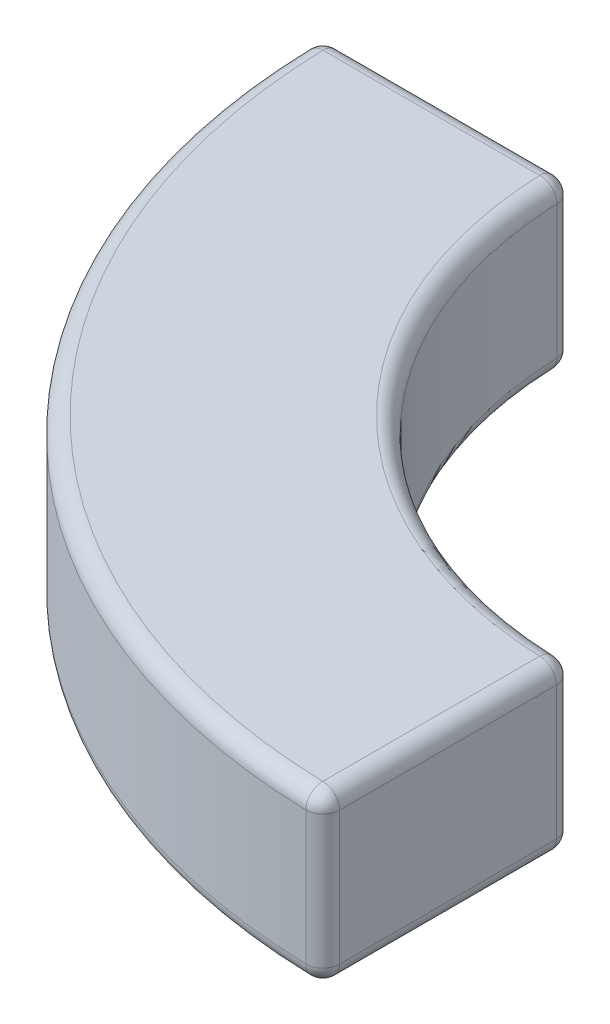
from build123d import *

# Parameters (mm, degrees)
BOSS_EXTRUDE1_DEPTH = 5
FILLET1_R           = 0.5


with BuildPart() as part:
    # Sketch1 → Boss-Extrude1 (new body)
    with BuildSketch(Plane(origin=(0, 0, 0), x_dir=(1, 0, 0), z_dir=(0, 1, 0))):
        with BuildLine():
            Line((-12.5, 0), (-20, 0))
            ThreePointArc((-20, 0), (-14.142135624, -14.142135624), (0, -20))
            Line((0, -20), (0, -12.5))
            ThreePointArc((0, -12.5), (-8.838834765, -8.838834765), (-12.5, 0))
        make_face()
    extrude(amount=BOSS_EXTRUDE1_DEPTH)

    # Fillet1
    fillet1_edges = [part.edges().sort_by_distance(p)[0] for p in [
        (-14.142135624, 5, 14.142135624),
        (0, 5, 16.25),
        (-8.838834765, 5, 8.838834765),
        (0, 0, 16.25),
        (-14.142135624, 0, 14.142135624),
        (-16.25, 0, 0),
        (-8.838834765, 0, 8.838834765),
        (0, 2.5, 12.5),
        (0, 2.5, 20),
        (-20, 2.5, 0),
        (-12.5, 2.5, 0),
        (-16.25, 5, 0),
    ]]
    fillet(fillet1_edges, radius=FILLET1_R)


solid = part.part
